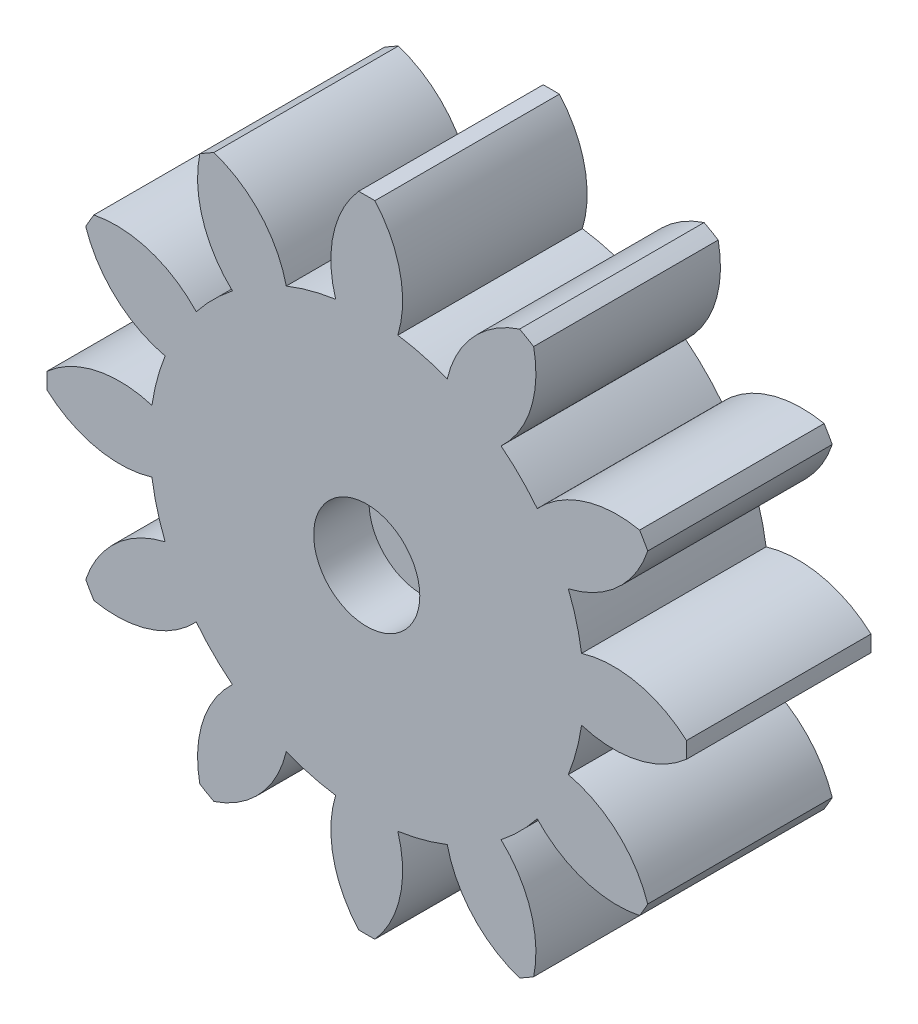
from build123d import *

# Parameters (mm, degrees)
BOSS_EXTRUDE1_DEPTH = 10
SKETCH3_R           = 2.875
CUT_EXTRUDE1_DEPTH  = 3
SKETCH4_R           = 2.875
CUT_EXTRUDE2_DEPTH  = 5
CUT_EXTRUDE3_REACH  = 7
SKETCH5_R           = 1.375
CUT_EXTRUDE4_DEPTH  = 0.4


with BuildPart() as part:
    # Sketch1 → Boss-Extrude1 (new body)
    with BuildSketch(Plane.XY):
        with BuildLine():
            ThreePointArc((10.92443124, -4.361437941), (11.362069294, -3.044457292), (11.641553947, -1.685099566))
            ThreePointArc((11.641553947, -1.685099566), (14.648632583, -1.806960077), (17.329910897, -0.440168758))
            ThreePointArc((17.329910897, -0.440168758), (17.3355, 0), (17.329910897, 0.440168758))
            ThreePointArc((17.329910897, 0.440168758), (14.648632583, 1.806960077), (11.641553947, 1.685099566))
            ThreePointArc((11.641553947, 1.685099566), (11.362069294, 3.044457292), (10.92443124, 4.361437941))
            ThreePointArc((10.92443124, 4.361437941), (13.589567986, 5.759442961), (15.228227462, 8.283758122))
            ThreePointArc((15.228227462, 8.283758122), (15.012983387, 8.66775), (14.788058703, 9.046152775))
            ThreePointArc((14.788058703, 9.046152775), (11.782607909, 8.889189622), (9.239331674, 7.280116005))
            ThreePointArc((9.239331674, 7.280116005), (8.317612002, 8.317612002), (7.280116005, 9.239331674))
            ThreePointArc((7.280116005, 9.239331674), (8.889189622, 11.782607909), (9.046152775, 14.788058703))
            ThreePointArc((9.046152775, 14.788058703), (8.66775, 15.012983387), (8.283758122, 15.228227462))
            ThreePointArc((8.283758122, 15.228227462), (5.759442961, 13.589567986), (4.361437941, 10.92443124))
            ThreePointArc((4.361437941, 10.92443124), (3.044457292, 11.362069294), (1.685099566, 11.641553947))
            ThreePointArc((1.685099566, 11.641553947), (1.806960077, 14.648632583), (0.440168758, 17.329910897))
            ThreePointArc((0.440168758, 17.329910897), (0, 17.3355), (-0.440168758, 17.329910897))
            ThreePointArc((-0.440168758, 17.329910897), (-1.806960077, 14.648632583), (-1.685099566, 11.641553947))
            ThreePointArc((-1.685099566, 11.641553947), (-3.044457292, 11.362069294), (-4.361437941, 10.92443124))
            ThreePointArc((-4.361437941, 10.92443124), (-5.759442961, 13.589567986), (-8.283758122, 15.228227462))
            ThreePointArc((-8.283758122, 15.228227462), (-8.66775, 15.012983387), (-9.046152775, 14.788058703))
            ThreePointArc((-9.046152775, 14.788058703), (-8.889189622, 11.782607909), (-7.280116005, 9.239331674))
            ThreePointArc((-7.280116005, 9.239331674), (-8.317612002, 8.317612002), (-9.239331674, 7.280116005))
            ThreePointArc((-9.239331674, 7.280116005), (-11.782607909, 8.889189622), (-14.788058703, 9.046152775))
            ThreePointArc((-14.788058703, 9.046152775), (-15.012983387, 8.66775), (-15.228227462, 8.283758122))
            ThreePointArc((-15.228227462, 8.283758122), (-13.589567986, 5.759442961), (-10.92443124, 4.361437941))
            ThreePointArc((-10.92443124, 4.361437941), (-11.362069294, 3.044457292), (-11.641553947, 1.685099566))
            ThreePointArc((-11.641553947, 1.685099566), (-14.648632583, 1.806960077), (-17.329910897, 0.440168758))
            ThreePointArc((-17.329910897, 0.440168758), (-17.3355, 0), (-17.329910897, -0.440168758))
            ThreePointArc((-17.329910897, -0.440168758), (-14.648632583, -1.806960077), (-11.641553947, -1.685099566))
            ThreePointArc((-11.641553947, -1.685099566), (-11.362069294, -3.044457292), (-10.92443124, -4.361437941))
            ThreePointArc((-10.92443124, -4.361437941), (-13.589567986, -5.759442961), (-15.228227462, -8.283758122))
            ThreePointArc((-15.228227462, -8.283758122), (-15.012983387, -8.66775), (-14.788058703, -9.046152775))
            ThreePointArc((-14.788058703, -9.046152775), (-11.782607909, -8.889189622), (-9.239331674, -7.280116005))
            ThreePointArc((-9.239331674, -7.280116005), (-8.317612002, -8.317612002), (-7.280116005, -9.239331674))
            ThreePointArc((-7.280116005, -9.239331674), (-8.889189622, -11.782607909), (-9.046152775, -14.788058703))
            ThreePointArc((-9.046152775, -14.788058703), (-8.66775, -15.012983387), (-8.283758122, -15.228227462))
            ThreePointArc((-8.283758122, -15.228227462), (-5.759442961, -13.589567986), (-4.361437941, -10.92443124))
            ThreePointArc((-4.361437941, -10.92443124), (-3.044457292, -11.362069294), (-1.685099566, -11.641553947))
            ThreePointArc((-1.685099566, -11.641553947), (-1.806960077, -14.648632583), (-0.440168758, -17.329910897))
            ThreePointArc((-0.440168758, -17.329910897), (0, -17.3355), (0.440168758, -17.329910897))
            ThreePointArc((0.440168758, -17.329910897), (1.806960077, -14.648632583), (1.685099566, -11.641553947))
            ThreePointArc((1.685099566, -11.641553947), (3.044457292, -11.362069294), (4.361437941, -10.92443124))
            ThreePointArc((4.361437941, -10.92443124), (5.759442961, -13.589567986), (8.283758122, -15.228227462))
            ThreePointArc((8.283758122, -15.228227462), (8.66775, -15.012983387), (9.046152775, -14.788058703))
            ThreePointArc((9.046152775, -14.788058703), (8.889189622, -11.782607909), (7.280116005, -9.239331674))
            ThreePointArc((7.280116005, -9.239331674), (8.317612002, -8.317612002), (9.239331674, -7.280116005))
            ThreePointArc((9.239331674, -7.280116005), (11.782607909, -8.889189622), (14.788058703, -9.046152775))
            ThreePointArc((14.788058703, -9.046152775), (15.012983387, -8.66775), (15.228227462, -8.283758122))
            ThreePointArc((15.228227462, -8.283758122), (13.589567986, -5.759442961), (10.92443124, -4.361437941))
        make_face()
    extrude(amount=BOSS_EXTRUDE1_DEPTH)

    # Sketch3 → Cut-Extrude1 (cut)
    with BuildSketch(Plane.XY.offset(10)):
        Circle(SKETCH3_R)
    extrude(amount=-CUT_EXTRUDE1_DEPTH, mode=Mode.SUBTRACT)

    # Sketch4 → Cut-Extrude2 (cut)
    with BuildSketch(Plane(origin=(0, 0, 0), x_dir=(-1, 0, 0), z_dir=(0, 0, -1))):
        Circle(SKETCH4_R)
    extrude(amount=-CUT_EXTRUDE2_DEPTH, mode=Mode.SUBTRACT)

    # Sketch5 → Cut-Extrude3 (cut, up to next)
    with BuildSketch(Plane(origin=(0, 0, 5), x_dir=(-1, 0, 0), z_dir=(0, 0, -1)), mode=Mode.PRIVATE) as cut_extrude3_sk1:
        Circle(SKETCH5_R)
    cut_extrude3_tool1 = extrude(cut_extrude3_sk1.sketch, amount=-CUT_EXTRUDE3_REACH, mode=Mode.PRIVATE) & part.part
    add(cut_extrude3_tool1.solids().sort_by_distance((0, 0, 5))[0], mode=Mode.SUBTRACT)

    # Sketch6 → Cut-Extrude4 (cut)
    with BuildSketch(Plane(origin=(0, 0, 0), x_dir=(-1, 0, 0), z_dir=(0, 0, -1))):
        with BuildLine():
            add(Edge.make_bspline(
                [(-5.479737052, 4.373698183), (-5.446887427, 4.37193719), (-5.382752567, 4.36849907), (-5.291014853, 4.340523863), (-5.207118443, 4.295161515), (-5.134075042, 4.232274652), (-5.071791468, 4.158364543), (-5.026849631, 4.074631791), (-5.000271189, 3.983493218), (-4.996560504, 3.920674078), (-4.994667607, 3.888628738)],
                knots=[0, 0, 0, 0, 9.839e-05, 0.000192094, 0.000284968, 0.000382609, 0.000479502, 0.000573402, 0.000665658, 0.000761727, 0.000761727, 0.000761727, 0.000761727], degree=3))
            add(Edge.make_bspline(
                [(-4.994667607, 3.888628738), (-4.996560504, 3.856583398), (-5.000271189, 3.793764258), (-5.026849631, 3.702625685), (-5.071791468, 3.618892933), (-5.134075042, 3.544982824), (-5.207118443, 3.482095961), (-5.291014853, 3.436733614), (-5.382752567, 3.408758407), (-5.446887427, 3.405320286), (-5.479737052, 3.403559294)],
                knots=[0, 0, 0, 0, 9.6069e-05, 0.000188325, 0.000282225, 0.000379118, 0.000476759, 0.000569633, 0.000663337, 0.000761727, 0.000761727, 0.000761727, 0.000761727], degree=3))
            add(Edge.make_bspline(
                [(-5.479737052, 3.403559294), (-5.512586676, 3.405320286), (-5.576721536, 3.408758407), (-5.66845925, 3.436733614), (-5.75235566, 3.482095961), (-5.825399061, 3.544982824), (-5.887682635, 3.618892933), (-5.932624473, 3.702625685), (-5.959202914, 3.793764258), (-5.962913599, 3.856583398), (-5.964806496, 3.888628738)],
                knots=[0, 0, 0, 0, 9.839e-05, 0.000192094, 0.000284968, 0.000382609, 0.000479502, 0.000573402, 0.000665658, 0.000761727, 0.000761727, 0.000761727, 0.000761727], degree=3))
            add(Edge.make_bspline(
                [(-5.964806496, 3.888628738), (-5.962913599, 3.920674078), (-5.959202914, 3.983493218), (-5.932624473, 4.074631791), (-5.887682635, 4.158364543), (-5.825399061, 4.232274652), (-5.75235566, 4.295161515), (-5.66845925, 4.340523863), (-5.576721536, 4.36849907), (-5.512586676, 4.37193719), (-5.479737052, 4.373698183)],
                knots=[0, 0, 0, 0, 9.6069e-05, 0.000188325, 0.000282225, 0.000379118, 0.000476759, 0.000569633, 0.000663337, 0.000761727, 0.000761727, 0.000761727, 0.000761727], degree=3))
        make_face()
        Polygon((-3.266607711, 9.299018695), (0.453035384, 9.299018695), (-3.390207137, 3.328933225), (-3.785492093, 3.655422274), (-0.489118729, 8.776636217), (-3.352894103, 8.776636217), align=None)
        with BuildLine():
            Line((2.318687094, 9.299018695), (4.632095213, 9.299018695))
            Line((4.632095213, 9.299018695), (4.557469145, 8.776636217))
            Line((4.557469145, 8.776636217), (2.697647597, 8.776636217))
            Line((2.697647597, 8.776636217), (2.251057219, 7.338918368))
            add(Edge.make_bspline(
                [(2.251057219, 7.338918368), (2.281376529, 7.341600763), (2.338895932, 7.346689591), (2.420795645, 7.354528554), (2.493562715, 7.35783457), (2.539065408, 7.358454804), (2.560055784, 7.358740918)],
                knots=[0, 0, 0, 0, 9.1316e-05, 0.000173238, 0.000246781, 0.000309757, 0.000309757, 0.000309757, 0.000309757], degree=3))
            add(Edge.make_bspline(
                [(2.560055784, 7.358740918), (2.629097715, 7.35583168), (2.767128952, 7.350015421), (2.970788893, 7.302493959), (3.168952118, 7.225239078), (3.360529688, 7.119781499), (3.53938682, 6.985546631), (3.702452922, 6.826913065), (3.843878862, 6.641785132), (3.964293972, 6.434712765), (4.061524524, 6.210786548), (4.13377311, 5.974414215), (4.176421409, 5.727065278), (4.181678325, 5.558550488), (4.184338803, 5.473266659)],
                knots=[0, 0, 0, 0, 0.000206944, 0.00041373, 0.000623774, 0.00084349, 0.001067602, 0.001292706, 0.001523834, 0.001764218, 0.002009653, 0.002254581, 0.002504169, 0.002759913, 0.002759913, 0.002759913, 0.002759913], degree=3))
            add(Edge.make_bspline(
                [(4.184338803, 5.473266659), (4.183352396, 5.425044423), (4.181384142, 5.328822907), (4.168335693, 5.185904094), (4.147071445, 5.045028829), (4.118617764, 4.906498732), (4.079215817, 4.770525235), (4.033093178, 4.636774893), (3.977719486, 4.505165198), (3.914322211, 4.376993978), (3.843116583, 4.254002982), (3.767708057, 4.137272529), (3.68682921, 4.028109415), (3.600394249, 3.926387748), (3.508424649, 3.832148967), (3.411440499, 3.745092909), (3.308255088, 3.667302411), (3.201178697, 3.595722898), (3.089091634, 3.533023925), (2.973952909, 3.478072585), (2.855038284, 3.432100729), (2.732755614, 3.395607611), (2.607362982, 3.364211073), (2.478231713, 3.343658369), (2.345716485, 3.332140741), (2.2565206, 3.330010526), (2.21141212, 3.328933225)],
                knots=[0, 0, 0, 0, 0.000144663, 0.000288658, 0.000430147, 0.000571934, 0.00071256, 0.000854534, 0.000996163, 0.001140609, 0.001283214, 0.001422285, 0.001557313, 0.001690491, 0.001822423, 0.001952084, 0.00208105, 0.002209763, 0.002338196, 0.002465982, 0.002592226, 0.002720219, 0.002848615, 0.002979736, 0.003112012, 0.003247352, 0.003247352, 0.003247352, 0.003247352], degree=3))
            add(Edge.make_bspline(
                [(2.21141212, 3.328933225), (2.16396587, 3.329851256), (2.070030352, 3.331668801), (1.931137364, 3.345473936), (1.796968333, 3.3706609), (1.666418728, 3.402720758), (1.540655136, 3.446233136), (1.41893022, 3.498665311), (1.301845272, 3.561106939), (1.188254643, 3.632011908), (1.079602645, 3.714150269), (0.975266388, 3.806692457), (0.876181435, 3.910433424), (0.783132268, 4.026241385), (0.69169693, 4.150156429), (0.606678686, 4.286533432), (0.526100484, 4.433320564), (0.477729789, 4.536657942), (0.453035384, 4.589414161)],
                knots=[0, 0, 0, 0, 0.000142332, 0.000281794, 0.000418105, 0.000551589, 0.000684706, 0.000816838, 0.000948806, 0.001082418, 0.001218144, 0.001356907, 0.001500409, 0.00164792, 0.001802317, 0.001962132, 0.002129639, 0.00230435, 0.00230435, 0.00230435, 0.00230435], degree=3))
            Line((0.453035384, 4.589414161), (0.988244218, 4.821454593))
            add(Edge.make_bspline(
                [(0.988244218, 4.821454593), (1.005255878, 4.78236131), (1.038712367, 4.705477339), (1.096059706, 4.596306995), (1.156748465, 4.494026152), (1.222163227, 4.399319237), (1.291904013, 4.312040812), (1.365787196, 4.231960872), (1.444101322, 4.159872477), (1.551444797, 4.073166135), (1.695405641, 3.986057221), (1.876162682, 3.907244777), (2.065596651, 3.859959615), (2.194442019, 3.854207566), (2.259219445, 3.851315704)],
                knots=[0, 0, 0, 0, 0.000127865, 0.00025147, 0.000369655, 0.000484478, 0.000596471, 0.000704561, 0.000811002, 0.00091553, 0.001118114, 0.00131348, 0.001505507, 0.001699661, 0.001699661, 0.001699661, 0.001699661], degree=3))
            add(Edge.make_bspline(
                [(2.259219445, 3.851315704), (2.303208236, 3.85274706), (2.390465379, 3.855586331), (2.519614288, 3.875711184), (2.645208809, 3.910164662), (2.768426821, 3.956964553), (2.888689814, 4.017477291), (3.004576765, 4.093412356), (3.117887536, 4.18130084), (3.228001329, 4.280525189), (3.330749603, 4.391340263), (3.419183478, 4.514347811), (3.494597313, 4.646422495), (3.556720693, 4.787305529), (3.602692959, 4.938704792), (3.638342764, 5.097947009), (3.657801791, 5.267564902), (3.660546567, 5.38343647), (3.661956324, 5.442949819)],
                knots=[0, 0, 0, 0, 0.000131947, 0.000261734, 0.000391, 0.000522017, 0.000656556, 0.000794014, 0.000936985, 0.001086406, 0.001238259, 0.001389398, 0.001539812, 0.001693843, 0.001850213, 0.002013745, 0.002182819, 0.00236136, 0.00236136, 0.00236136, 0.00236136], degree=3))
            add(Edge.make_bspline(
                [(3.661956324, 5.442949819), (3.660787094, 5.493134291), (3.658487659, 5.591828159), (3.641907231, 5.736105749), (3.615435234, 5.87357755), (3.577227029, 6.003444193), (3.526138201, 6.125606727), (3.465979554, 6.24117438), (3.394202788, 6.349537486), (3.31159483, 6.449071773), (3.221073681, 6.5396656), (3.124167776, 6.620132131), (3.019693798, 6.686036929), (2.910546784, 6.742226352), (2.794297431, 6.783737985), (2.672077661, 6.814136504), (2.543953066, 6.833398887), (2.456346825, 6.83536334), (2.411969679, 6.836358439)],
                knots=[0, 0, 0, 0, 0.000150531, 0.000296038, 0.000435075, 0.000570103, 0.000701327, 0.000831719, 0.000960433, 0.00109047, 0.001219094, 0.001344207, 0.001467443, 0.001588946, 0.001711778, 0.001836778, 0.001966391, 0.002099447, 0.002099447, 0.002099447, 0.002099447], degree=3))
            add(Edge.make_bspline(
                [(2.411969679, 6.836358439), (2.339135462, 6.833693433), (2.189851737, 6.828231138), (1.962219145, 6.788444284), (1.726127633, 6.726214825), (1.569961928, 6.665740044), (1.489638115, 6.634634848)],
                knots=[0, 0, 0, 0, 0.000218425, 0.000447692, 0.000691501, 0.000949719, 0.000949719, 0.000949719, 0.000949719], degree=3))
            Line((1.489638115, 6.634634848), (2.318687094, 9.299018695))
        make_face()
    extrude(amount=-CUT_EXTRUDE4_DEPTH, mode=Mode.SUBTRACT)


solid = part.part
